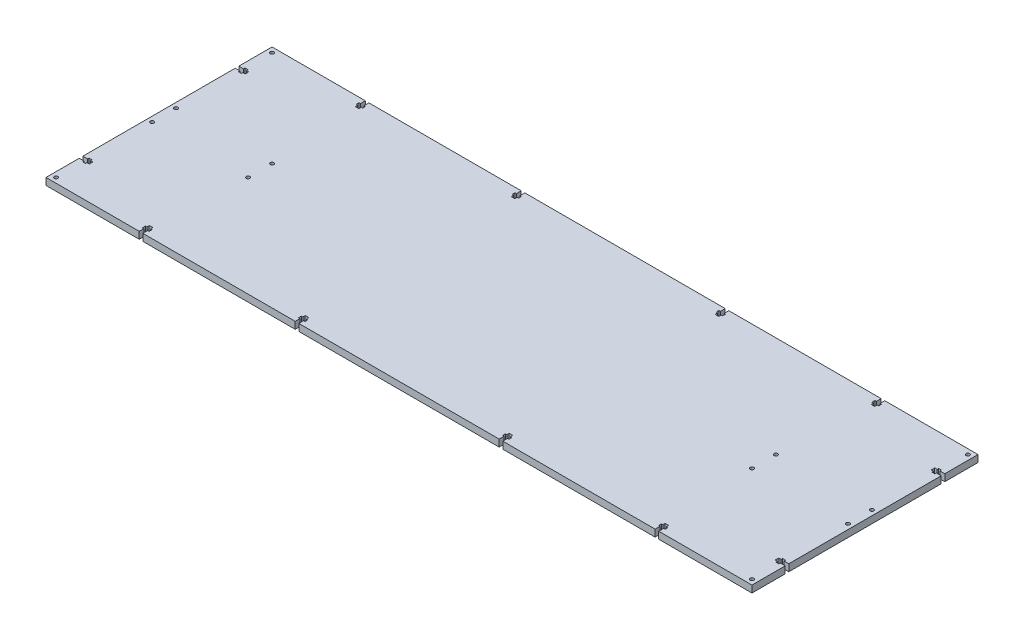
from build123d import *

# Parameters (mm, degrees)
SKETCH1_W           = 588.4
SKETCH1_H           = 5.8
BOSS_EXTRUDE1_DEPTH = 188.4
CUT_EXTRUDE1_DEPTH  = 5.8
CUT_EXTRUDE2_DEPTH  = 5.8
SKETCH5_W           = 588.4
SKETCH5_H           = 10.208859739
SKETCH5_H_2         = 13.85
BOSS_EXTRUDE2_DEPTH = 5.8
CUT_EXTRUDE4_DEPTH  = 5.8
SKETCH8_R           = 1.5
CUT_EXTRUDE6_DEPTH  = 5.8


with BuildPart() as part:
    # Sketch1 → Boss-Extrude1 (new body)
    with BuildSketch(Plane.XY):
        with Locations((294.2, 2.9)):
            Rectangle(SKETCH1_W, SKETCH1_H)
    extrude(amount=BOSS_EXTRUDE1_DEPTH)

    # Sketch2 → Cut-Extrude1 (cut)
    with BuildSketch(Plane(origin=(0, 5.8, 0), x_dir=(1, 0, 0), z_dir=(0, 1, 0))):
        Polygon((27.7, -184.4), (27.7, -188.4), (30.7, -188.4), (30.7, -184.4), (31.91, -184.4), (31.91, -182.05), (30.7, -182.05), (30.7, -180.05), (27.7, -180.05), (27.7, -182.05), (26.49, -182.05), (26.49, -184.4), align=None)
        Polygon((157.7, -184.4), (157.7, -188.4), (160.7, -188.4), (160.7, -184.4), (161.91, -184.4), (161.91, -182.05), (160.7, -182.05), (160.7, -180.05), (157.7, -180.05), (157.7, -182.05), (156.49, -182.05), (156.49, -184.4), align=None)
        Polygon((227.7, -184.4), (227.7, -188.4), (230.7, -188.4), (230.7, -184.4), (231.91, -184.4), (231.91, -182.05), (230.7, -182.05), (230.7, -180.05), (227.7, -180.05), (227.7, -182.05), (226.49, -182.05), (226.49, -184.4), align=None)
        Polygon((357.7, -184.4), (357.7, -188.4), (360.7, -188.4), (360.7, -184.4), (361.91, -184.4), (361.91, -182.05), (360.7, -182.05), (360.7, -180.05), (357.7, -180.05), (357.7, -182.05), (356.49, -182.05), (356.49, -184.4), align=None)
        Polygon((427.7, -184.4), (427.7, -188.4), (430.7, -188.4), (430.7, -184.4), (431.91, -184.4), (431.91, -182.05), (430.7, -182.05), (430.7, -180.05), (427.7, -180.05), (427.7, -182.05), (426.49, -182.05), (426.49, -184.4), align=None)
        Polygon((557.7, -188.4), (560.7, -188.4), (560.7, -184.4), (561.91, -184.4), (561.91, -182.05), (560.7, -182.05), (560.7, -180.05), (557.7, -180.05), (557.7, -182.05), (556.49, -182.05), (556.49, -184.4), (557.7, -184.4), align=None)
        Polygon((560.7, 0), (557.7, 0), (557.7, -4), (556.49, -4), (556.49, -6.35), (557.7, -6.35), (557.7, -8.35), (560.7, -8.35), (560.7, -6.35), (561.91, -6.35), (561.91, -4), (560.7, -4), align=None)
        Polygon((430.7, 0), (427.7, 0), (427.7, -4), (426.49, -4), (426.49, -6.35), (427.7, -6.35), (427.7, -8.35), (430.7, -8.35), (430.7, -6.35), (431.91, -6.35), (431.91, -4), (430.7, -4), align=None)
        Polygon((360.7, 0), (357.7, 0), (357.7, -4), (356.49, -4), (356.49, -6.35), (357.7, -6.35), (357.7, -8.35), (360.7, -8.35), (360.7, -6.35), (361.91, -6.35), (361.91, -4), (360.7, -4), align=None)
        Polygon((230.7, 0), (227.7, 0), (227.7, -4), (226.49, -4), (226.49, -6.35), (227.7, -6.35), (227.7, -8.35), (230.7, -8.35), (230.7, -6.35), (231.91, -6.35), (231.91, -4), (230.7, -4), align=None)
        Polygon((160.7, 0), (157.7, 0), (157.7, -4), (156.49, -4), (156.49, -6.35), (157.7, -6.35), (157.7, -8.35), (160.7, -8.35), (160.7, -6.35), (161.91, -6.35), (161.91, -4), (160.7, -4), align=None)
        Polygon((30.7, -8.35), (30.7, -6.35), (31.91, -6.35), (31.91, -4), (30.7, -4), (30.7, 0), (27.7, 0), (27.7, -4), (26.49, -4), (26.49, -6.35), (27.7, -6.35), (27.7, -8.35), align=None)
    extrude(amount=-CUT_EXTRUDE1_DEPTH, mode=Mode.SUBTRACT)

    # Sketch2_3 → Cut-Extrude2 (cut)
    with BuildSketch(Plane(origin=(0, 5.8, 0), x_dir=(1, 0, 0), z_dir=(0, 1, 0))):
        Polygon((8.35, -27.7), (6.35, -27.7), (6.35, -26.49), (4, -26.49), (4, -27.7), (0, -27.7), (0, -30.7), (4, -30.7), (4, -31.91), (6.35, -31.91), (6.35, -30.7), (8.35, -30.7), align=None)
        Polygon((4, -157.7), (0, -157.7), (0, -160.7), (4, -160.7), (4, -161.91), (6.35, -161.91), (6.35, -160.7), (8.35, -160.7), (8.35, -157.7), (6.35, -157.7), (6.35, -156.49), (4, -156.49), align=None)
        Polygon((580.05, -160.7), (582.05, -160.7), (582.05, -161.91), (584.4, -161.91), (584.4, -160.7), (588.4, -160.7), (588.4, -157.7), (584.4, -157.7), (584.4, -156.49), (582.05, -156.49), (582.05, -157.7), (580.05, -157.7), align=None)
        Polygon((584.4, -30.7), (588.4, -30.7), (588.4, -27.7), (584.4, -27.7), (584.4, -26.49), (582.05, -26.49), (582.05, -27.7), (580.05, -27.7), (580.05, -30.7), (582.05, -30.7), (582.05, -31.91), (584.4, -31.91), align=None)
    extrude(amount=-CUT_EXTRUDE2_DEPTH, mode=Mode.SUBTRACT)

    # Sketch5 → Boss-Extrude2 (add)
    with BuildSketch(Plane.XZ):
        with Locations((294.2, 183.295570131)):
            Rectangle(SKETCH5_W, SKETCH5_H)
        with Locations((294.2, 6.925)):
            Rectangle(SKETCH5_W, SKETCH5_H_2)
    extrude(amount=-BOSS_EXTRUDE2_DEPTH)

    # Sketch6 → Cut-Extrude4 (cut)
    with BuildSketch(Plane.XZ):
        Polygon((77.7, 188.4), (80.7, 188.4), (80.7, 184.4), (81.91, 184.4), (81.91, 182.05), (80.7, 182.05), (80.7, 180.05), (77.7, 180.05), (77.7, 182.05), (76.49, 182.05), (76.49, 184.4), (77.7, 184.4), align=None)
        Polygon((210.7, 180.05), (210.7, 182.05), (211.91, 182.05), (211.91, 184.4), (210.7, 184.4), (210.7, 188.4), (207.7, 188.4), (207.7, 184.4), (206.49, 184.4), (206.49, 182.05), (207.7, 182.05), (207.7, 180.05), align=None)
        Polygon((377.7, 188.4), (380.7, 188.4), (380.7, 184.4), (381.91, 184.4), (381.91, 182.05), (380.7, 182.05), (380.7, 180.05), (377.7, 180.05), (377.7, 182.05), (376.49, 182.05), (376.49, 184.4), (377.7, 184.4), align=None)
        Polygon((510.7, 180.05), (510.7, 182.05), (511.91, 182.05), (511.91, 184.4), (510.7, 184.4), (510.7, 188.4), (507.7, 188.4), (507.7, 184.4), (506.49, 184.4), (506.49, 182.05), (507.7, 182.05), (507.7, 180.05), align=None)
        Polygon((510.7, 0), (507.7, 0), (507.7, 4), (506.49, 4), (506.49, 6.35), (507.7, 6.35), (507.7, 8.35), (510.7, 8.35), (510.7, 6.35), (511.91, 6.35), (511.91, 4), (510.7, 4), align=None)
        Polygon((377.7, 8.35), (377.7, 6.35), (376.49, 6.35), (376.49, 4), (377.7, 4), (377.7, 0), (380.7, 0), (380.7, 4), (381.91, 4), (381.91, 6.35), (380.7, 6.35), (380.7, 8.35), align=None)
        Polygon((210.7, 0), (207.7, 0), (207.7, 4), (206.49, 4), (206.49, 6.35), (207.7, 6.35), (207.7, 8.35), (210.7, 8.35), (210.7, 6.35), (211.91, 6.35), (211.91, 4), (210.7, 4), align=None)
        Polygon((77.7, 8.35), (77.7, 6.35), (76.49, 6.35), (76.49, 4), (77.7, 4), (77.7, 0), (80.7, 0), (80.7, 4), (81.91, 4), (81.91, 6.35), (80.7, 6.35), (80.7, 8.35), align=None)
    extrude(amount=-CUT_EXTRUDE4_DEPTH, mode=Mode.SUBTRACT)

    # Sketch8 → Cut-Extrude6 (cut)
    with BuildSketch(Plane(origin=(0, 5.8, 0), x_dir=(1, 0, 0), z_dir=(0, 1, 0))):
        with Locations((4.2, -4.2)):
            Circle(SKETCH8_R)
        with Locations((4.2, -84.2)):
            Circle(SKETCH8_R)
        with Locations((84.2, -84.2)):
            Circle(SKETCH8_R)
        with Locations((84.2, -104.2)):
            Circle(SKETCH8_R)
        with Locations((4.2, -104.2)):
            Circle(SKETCH8_R)
        with Locations((4.2, -184.2)):
            Circle(SKETCH8_R)
        with Locations((584.2, -184.2)):
            Circle(SKETCH8_R)
        with Locations((584.2, -104.2)):
            Circle(SKETCH8_R)
        with Locations((504.2, -104.2)):
            Circle(SKETCH8_R)
        with Locations((504.2, -84.2)):
            Circle(SKETCH8_R)
        with Locations((584.2, -84.2)):
            Circle(SKETCH8_R)
        with Locations((584.2, -4.2)):
            Circle(SKETCH8_R)
    extrude(amount=-CUT_EXTRUDE6_DEPTH, mode=Mode.SUBTRACT)


solid = part.part
